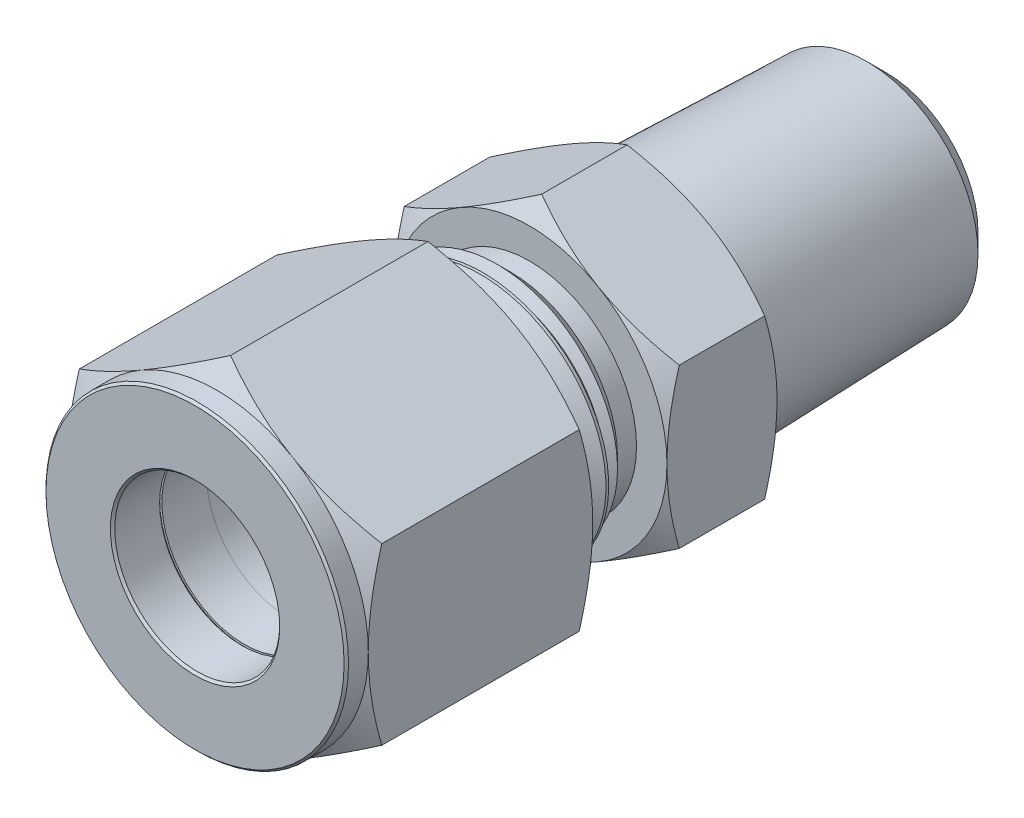
from build123d import *

# Parameters (mm, degrees)
BOSS_EXTRUDE1_DEPTH    = 14.224
CHAMFER1_SIZE          = 0.127
CUT_SWEEP1_PITCH       = 1.2700000000000078
CUT_SWEEP1_HEIGHT      = 19.55800000000008
CUT_SWEEP1_RADIUS      = 7.143750000000002
CUT_SWEEP1_START_ANGLE = 90.00000000000021
BOSS_EXTRUDE2_DEPTH    = 6.35


with BuildPart() as part:
    # Sketch2 → Boss-Extrude1 (new body)
    with BuildSketch(Plane.XY):
        Polygon((1.23e-15, 10.081979075723838), (-8.731249999999998, 5.0409895378619245), (-8.73125, -5.040989537861916), (-3.5e-15, -10.081979075723837), (8.731249999999998, -5.040989537861922), (8.731250000000003, 5.040989537861918), align=None)
    extrude(amount=-BOSS_EXTRUDE1_DEPTH)

    # Sketch3 → Cut-Revolve1 (revolve, cut)
    with BuildSketch(Plane(origin=(0, 0, 0), x_dir=(0, 0, -1), z_dir=(1, 0, 0)), mode=Mode.PRIVATE) as cut_revolve1_sk:
        Polygon((0, 10.081979075723838), (-8e-17, 8.73125), (1.2699999999999998, 8.73125), (2.0498437954714093, 10.081979075723837), (13.444156204528598, 10.08197907572384), (14.224, 8.73125), (14.224, 10.081979075723838), (14.224, 11.43270815144768), (-2.5e-16, 11.432708151447677), align=None)
        Polygon((9.7e-16, 4.7625), (8.7e-16, 0), (14.223999999999998, -2e-17), (14.223999999999997, 7.143750000000001), (5.6896, 7.14375), (5.6895999999999995, 6.508749999999999), (2.8447999999999998, 6.508749999999999), (2.8447999999999998, 5.873749999999997), (2.8447999999999998, 4.7625), align=None)
    revolve(cut_revolve1_sk.sketch.rotate(Axis((0, 0, 0), (0, 0, -1)), 90), axis=Axis((0, 0, 0), (0, 0, -1)), mode=Mode.SUBTRACT)

    # Chamfer1
    chamfer1_edges = [part.edges().sort_by_distance(p)[0] for p in [
        (-8.73125, -2.04e-15, 8e-17),
        (-4.7625, -1.11e-15, -2.8447999999999998),
        (-4.7625, -1.11e-15, -9.7e-16),
    ]]
    chamfer(chamfer1_edges, length=CHAMFER1_SIZE)


with BuildPart() as body_2:
    # Sketch4 → Revolve1 (revolve)
    with BuildSketch(Plane(origin=(0, 0, 0), x_dir=(0, 0, -1), z_dir=(1, 0, 0)), mode=Mode.PRIVATE) as revolve1_sk:
        Polygon((25.654000000000003, 0), (7.366000000000001, 0), (7.366000000000001, 7.14375), (25.654000000000003, 7.143750000000001), align=None)
    revolve(revolve1_sk.sketch.rotate(Axis((0, 0, -25.654000000000003), (0, 0, 1)), 90), axis=Axis((0, 0, -25.654000000000003), (0, 0, 1)))

    # Cut-Sweep1: sweep along a helix
    with BuildLine() as cut_sweep1_path:
        add(Helix(CUT_SWEEP1_PITCH, CUT_SWEEP1_HEIGHT, CUT_SWEEP1_RADIUS, center=(0, 0, -7.366000000000001), direction=(0, 0, -1), mode=Mode.PRIVATE).rotate(Axis((0, 0, -7.366000000000001), (0, 0, -1)), CUT_SWEEP1_START_ANGLE))
    # Sketch6 → Cut-Sweep1 (sweep, cut)
    with BuildSketch(Plane(origin=(0, 0, 0), x_dir=(0, 0, -1), z_dir=(1, 0, 0))):
        Polygon((6.731000000000001, 6.318860802895323), (6.2150625, 7.2124907664253906), (7.405687500000001, 7.2124907664253906), (6.88975, 6.318860802895323), align=None)
    sweep(path=cut_sweep1_path.line, is_frenet=True, mode=Mode.SUBTRACT)

    # Sketch7 → Boss-Extrude2 (add)
    with BuildSketch(Plane(origin=(0, 0, -25.654000000000003), x_dir=(-1, 0, 0), z_dir=(0, 0, -1))):
        Polygon((0, 9.165435523385309), (-7.9375, 4.582717761692655), (-7.9375, -4.582717761692655), (-4.1e-16, -9.165435523385309), (7.9375, -4.582717761692655), (7.937500000000002, 4.5827177616926535), align=None)
    extrude(amount=-BOSS_EXTRUDE2_DEPTH)

    # Sketch8 → Cut-Revolve2 (revolve, cut)
    with BuildSketch(Plane(origin=(0, 0, 0), x_dir=(0, 0, -1), z_dir=(1, 0, 0)), mode=Mode.PRIVATE) as cut_revolve2_sk:
        Polygon((7.366000000000001, 7.28123153285078), (7.366000000000001, 6.181379270044542), (8.465852262806237, 7.2812315328507795), align=None)
        Polygon((19.304, 7.28123153285078), (17.104295474387524, 7.28123153285078), (18.20414773719376, 6.181379270044543), (19.304, 6.181379270044543), align=None)
        Polygon((19.304000000000002, 7.9375), (20.012948904973996, 9.165435523385309), (24.94505109502601, 9.16543552338531), (25.654000000000007, 7.9375), (25.654000000000003, 9.165435523385309), (25.654000000000007, 10.393371046770618), (19.304, 10.393371046770618), (19.304, 9.165435523385309), align=None)
        Polygon((17.018, 3.5687), (25.654000000000003, 3.5687), (25.654000000000007, -3e-17), (7.366000000000001, 0), (7.366000000000001, 5.642404947916666), (10.922668421052633, 4.762500000000001), (17.018, 4.7625), align=None)
    revolve(cut_revolve2_sk.sketch.rotate(Axis((0, 0, 0), (0, 0, -1)), 90), axis=Axis((0, 0, 0), (0, 0, -1)), mode=Mode.SUBTRACT)


with BuildPart() as body_3:
    # Sketch9 → Revolve2 (revolve)
    with BuildSketch(Plane(origin=(0, 0, 0), x_dir=(0, 0, -1), z_dir=(1, 0, 0)), mode=Mode.PRIVATE) as revolve2_sk:
        Polygon((4.762499999999999, 6.286499999999999), (4.762499999999999, 5.4356), (5.4356, 4.762499999999998), (9.6393, 4.7625), (9.6393, 5.08), align=None)
    revolve(revolve2_sk.sketch.rotate(Axis((0, 0, 0), (0, 0, -1)), 90), axis=Axis((0, 0, 0), (0, 0, -1)))


with BuildPart() as body_4:
    # Sketch10 → Revolve3 (revolve)
    with BuildSketch(Plane(origin=(0, 0, 0), x_dir=(0, 0, -1), z_dir=(1, 0, 0)), mode=Mode.PRIVATE) as revolve3_sk:
        Polygon((2.8447999999999998, 6.222999999999999), (3.9877999999999996, 6.222999999999999), (3.9877999999999996, 5.435600000000001), (4.762499999999999, 5.4356), (5.4356, 4.762499999999998), (2.8447999999999998, 4.7624999999999975), align=None)
    revolve(revolve3_sk.sketch.rotate(Axis((0, 0, 0), (0, 0, -1)), 90), axis=Axis((0, 0, 0), (0, 0, -1)))


with BuildPart() as body_5:
    # Sketch11 → Revolve4 (revolve)
    with BuildSketch(Plane(origin=(0, 0, 0), x_dir=(0, 0, -1), z_dir=(1, 0, 0)), mode=Mode.PRIVATE) as revolve4_sk:
        Polygon((24.775160000000003, 0), (39.87800000000001, 0), (39.87800000000001, 6.387771669833238), (24.775160000000003, 6.8580000000000005), align=None)
    revolve(revolve4_sk.sketch.rotate(Axis((0, 0, -24.775160000000003), (0, 0, -1)), 90), axis=Axis((0, 0, -24.775160000000003), (0, 0, -1)))


with BuildPart() as body_2_1:
    add(body_2.part)

    # Combine1: union body 5
    add(body_5.part)

    # Sketch14 → Cut-Revolve4 (revolve, cut)
    with BuildSketch(Plane(origin=(0, 0, 0), x_dir=(0, 0, -1), z_dir=(1, 0, 0)), mode=Mode.PRIVATE) as cut_revolve4_sk:
        Polygon((39.87800000000001, 5.3184708587716205), (38.65594193021529, 6.54052892855633), (39.87800000000001, 6.54052892855633), align=None)
        Polygon((39.87800000000001, 4.6228), (24.775160000000003, 4.622799999999998), (21.997501530359415, 0), (39.87800000000001, 0), align=None)
    revolve(cut_revolve4_sk.sketch.rotate(Axis((0, 0, 0), (0, 0, -1)), 90), axis=Axis((0, 0, 0), (0, 0, -1)), mode=Mode.SUBTRACT)


solid = Compound([part.part, body_3.part, body_4.part, body_2_1.part])
